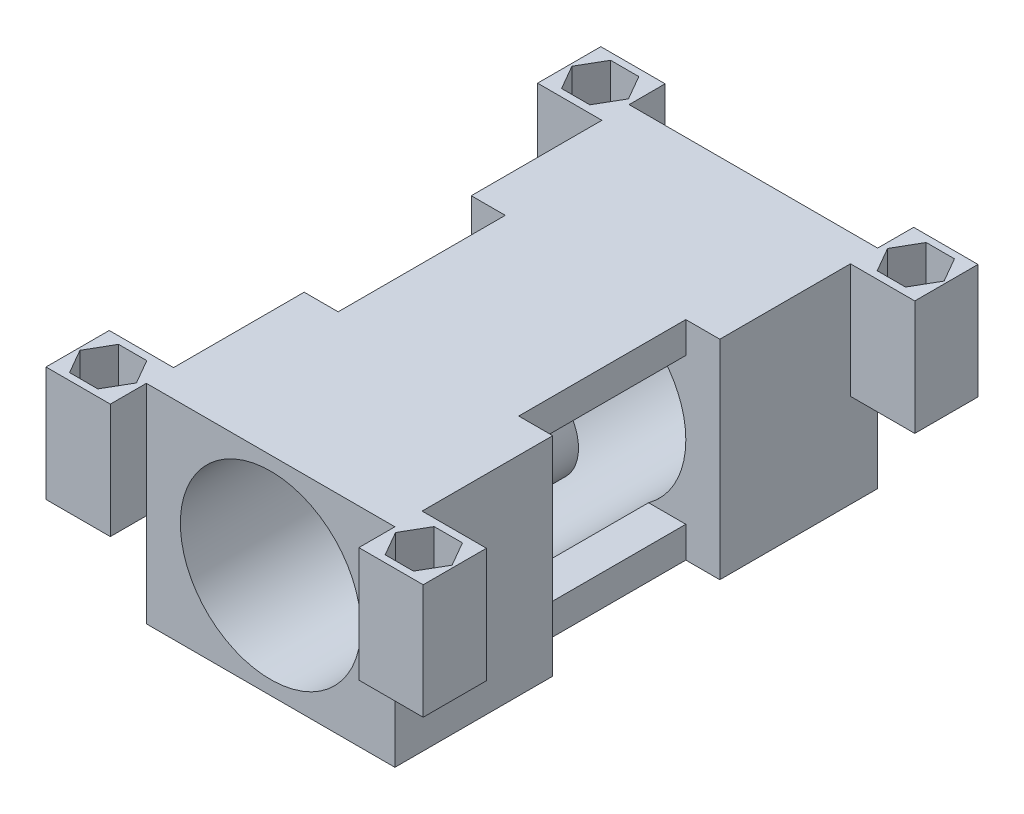
from build123d import *
from build123d.topology import SkipClean

# Parameters (mm, degrees)
SKETCH1_W                = 34
SKETCH1_H                = 28.5
BOSS_EXTRUDE1_DEPTH      = 66.04
SKETCH3_R                = 12.35
CUT_EXTRUDE1_DEPTH       = 70.665946488
SKETCH7_W                = 8.8
SKETCH7_H                = 15.7
BOSS_EXTRUDE2_DEPTH      = 4.93
BOSS_EXTRUDE2_DEPTH_BACK = 3.72
SKETCH10_W               = 8.8
SKETCH10_H               = 15.7
BOSS_EXTRUDE3_DEPTH      = 3.72
BOSS_EXTRUDE3_DEPTH_BACK = 4.93
CUT_EXTRUDE5_DEPTH       = 13
SKETCH11_R               = 12.35
BOSS_EXTRUDE4_DEPTH      = 2
CUT_EXTRUDE7_DEPTH       = 11.43
SKETCH14_R               = 6
BOSS_EXTRUDE5_DEPTH      = 3.1
SKETCH15_R               = 3.325
CUT_EXTRUDE8_DEPTH       = 2.5
SKETCH16_R               = 3.325
CUT_EXTRUDE9_DEPTH       = 2.5
SKETCH25_R               = 1.75
CUT_EXTRUDE17_DEPTH      = 50


with BuildPart() as part:
    # Sketch1 → Boss-Extrude1 (new body)
    with BuildSketch(Plane.XY):
        Rectangle(SKETCH1_W, SKETCH1_H)
    extrude(amount=BOSS_EXTRUDE1_DEPTH)

    # Sketch3 → Cut-Extrude1 (cut, through all)
    with BuildSketch(Plane.XY.offset(66.04)):
        Circle(SKETCH3_R)
    extrude(amount=-CUT_EXTRUDE1_DEPTH, mode=Mode.SUBTRACT)

    # Sketch7 → Boss-Extrude2 (add, two sides)
    with BuildSketch(Plane.XY.offset(66.04)) as boss_extrude2_sk:
        with Locations((-21.4, 6.4)):
            Rectangle(SKETCH7_W, SKETCH7_H)
        with Locations((21.4, 6.4)):
            Rectangle(SKETCH7_W, SKETCH7_H)
    extrude(amount=BOSS_EXTRUDE2_DEPTH)
    extrude(boss_extrude2_sk.sketch, amount=-BOSS_EXTRUDE2_DEPTH_BACK)

    # Sketch10 → Boss-Extrude3 (add, two sides)
    with BuildSketch(Plane.XY) as boss_extrude3_sk:
        with Locations((-21.4, 6.4)):
            Rectangle(SKETCH10_W, SKETCH10_H)
        with Locations((21.4, 6.4)):
            Rectangle(SKETCH10_W, SKETCH10_H)
    extrude(amount=BOSS_EXTRUDE3_DEPTH)
    extrude(boss_extrude3_sk.sketch, amount=-BOSS_EXTRUDE3_DEPTH_BACK)

    # Sketch8 → Cut-Extrude5 (cut)
    with BuildSketch(Plane(origin=(0, 14.25, 0), x_dir=(1, 0, 0), z_dir=(0, 1, 0))):
        Polygon((-25.458246804, 0.635), (-23.524123402, -2.715), (-19.655876598, -2.715), (-17.721753196, 0.635), (-19.655876598, 3.985), (-23.524123402, 3.985), align=None)
        Polygon((-17.721753196, -66.675), (-19.655876598, -63.325), (-23.524123402, -63.325), (-25.458246804, -66.675), (-23.524123402, -70.025), (-19.655876598, -70.025), align=None)
        Polygon((17.721753196, -66.675), (19.655876598, -70.025), (23.524123402, -70.025), (25.458246804, -66.675), (23.524123402, -63.325), (19.655876598, -63.325), align=None)
        Polygon((25.458246804, 0.635), (23.524123402, 3.985), (19.655876598, 3.985), (17.721753196, 0.635), (19.655876598, -2.715), (23.524123402, -2.715), align=None)
    extrude(amount=-CUT_EXTRUDE5_DEPTH, mode=Mode.SUBTRACT)


with BuildPart() as body_2:
    # Sketch11 → Boss-Extrude4 (new, symmetric)
    with BuildSketch(Plane.XY.offset(33.02)):
        Circle(SKETCH11_R)
    extrude(amount=BOSS_EXTRUDE4_DEPTH, both=True)


with BuildPart() as cut_extrude7_tool:
    # Sketch13 → Cut-Extrude7 (new, symmetric)
    with SkipClean():  # the faces are left unmerged after this step: merging them gives an invalid solid
        with BuildSketch(Plane.XY.offset(33.02)):
            with BuildLine():
                Line((17, -14.25), (17, 14.25))
                Line((17, 14.25), (12.35, 14.25))
                Line((12.35, 14.25), (12.35, 10))
                Line((12.35, 10), (7.247240854, 10))
                ThreePointArc((7.247240854, 10), (5.218397556, 11.193338508), (3, 11.980087646))
                Line((3, 11.980087646), (3, 0))
                Line((3, 0), (3, -11.980087646))
                ThreePointArc((3, -11.980087646), (5.218397556, -11.193338508), (7.247240854, -10))
                Line((7.247240854, -10), (12.35, -10))
                Line((12.35, -10), (12.35, -14.25))
                Line((12.35, -14.25), (17, -14.25))
            make_face()
            with BuildLine():
                Line((-12.35, 10), (-7.247240854, 10))
                ThreePointArc((-7.247240854, 10), (-5.218397556, 11.193338508), (-3, 11.980087646))
                Line((-3, 11.980087646), (-3, 0))
                Line((-3, 0), (-3, -11.980087646))
                ThreePointArc((-3, -11.980087646), (-5.218397556, -11.193338508), (-7.247240854, -10))
                Line((-7.247240854, -10), (-12.35, -10))
                Line((-12.35, -10), (-12.35, -14.25))
                Line((-12.35, -14.25), (-17, -14.25))
                Line((-17, -14.25), (-17, 14.25))
                Line((-17, 14.25), (-12.35, 14.25))
                Line((-12.35, 14.25), (-12.35, 10))
            make_face()
        extrude(amount=CUT_EXTRUDE7_DEPTH, both=True)


with BuildPart() as part_1:
    with SkipClean():  # the faces are left unmerged after this step: merging them gives an invalid solid
        add(part.part)

        # Cut-Extrude7: cut by cut_extrude7_tool
        add(cut_extrude7_tool.part, mode=Mode.SUBTRACT)



with BuildPart() as body_2_1:
    with SkipClean():  # the faces are left unmerged after this step: merging them gives an invalid solid
        add(body_2.part)

        # Cut-Extrude7: cut by cut_extrude7_tool
        add(cut_extrude7_tool.part, mode=Mode.SUBTRACT)


with BuildPart() as part_2:
    with SkipClean():  # the faces are left unmerged after this step: merging them gives an invalid solid
        add(part_1.part)

        add(body_2_1.part)  # Boss-Extrude5 merges body 2
        # Sketch14 → Boss-Extrude5 (add, symmetric)
        with BuildSketch(Plane.XY.offset(33.02)):
            Circle(SKETCH14_R)
        extrude(amount=BOSS_EXTRUDE5_DEPTH, both=True)

    # Sketch15 → Cut-Extrude8 (cut)
    with SkipClean():  # the faces are left unmerged after this step: merging them gives an invalid solid
        with BuildSketch(Plane.XY.offset(36.12)):
            Circle(SKETCH15_R)
        extrude(amount=-CUT_EXTRUDE8_DEPTH, mode=Mode.SUBTRACT)

    # Sketch16 → Cut-Extrude9 (cut)
    with SkipClean():  # the faces are left unmerged after this step: merging them gives an invalid solid
        with BuildSketch(Plane(origin=(0, 0, 29.92), x_dir=(-1, 0, 0), z_dir=(0, 0, -1))):
            with Locations(Location((0, 0, 0), (0, 0, 180))):
                Circle(SKETCH16_R)
        extrude(amount=-CUT_EXTRUDE9_DEPTH, mode=Mode.SUBTRACT)

    # Sketch25 → Cut-Extrude17 (cut)
    with SkipClean():  # the faces are left unmerged after this step: merging them gives an invalid solid
        with BuildSketch(Plane(origin=(132.323959999, 1.25, 1.846345109), x_dir=(1, 0, 0), z_dir=(0, 1, 0))):
            with Locations(Location((-110.733959999, 2.481345109, 0), (0, 0, 270))):
                Circle(SKETCH25_R)
            with Locations(Location((-110.733959999, -64.828654891, 0), (0, 0, 270))):
                Circle(SKETCH25_R)
            with Locations(Location((-153.913959999, -64.828654891, 0), (0, 0, 270))):
                Circle(SKETCH25_R)
            with Locations(Location((-153.913959999, 2.481345109, 0), (0, 0, 270))):
                Circle(SKETCH25_R)
        extrude(amount=-CUT_EXTRUDE17_DEPTH, mode=Mode.SUBTRACT)


solid = part_2.part
